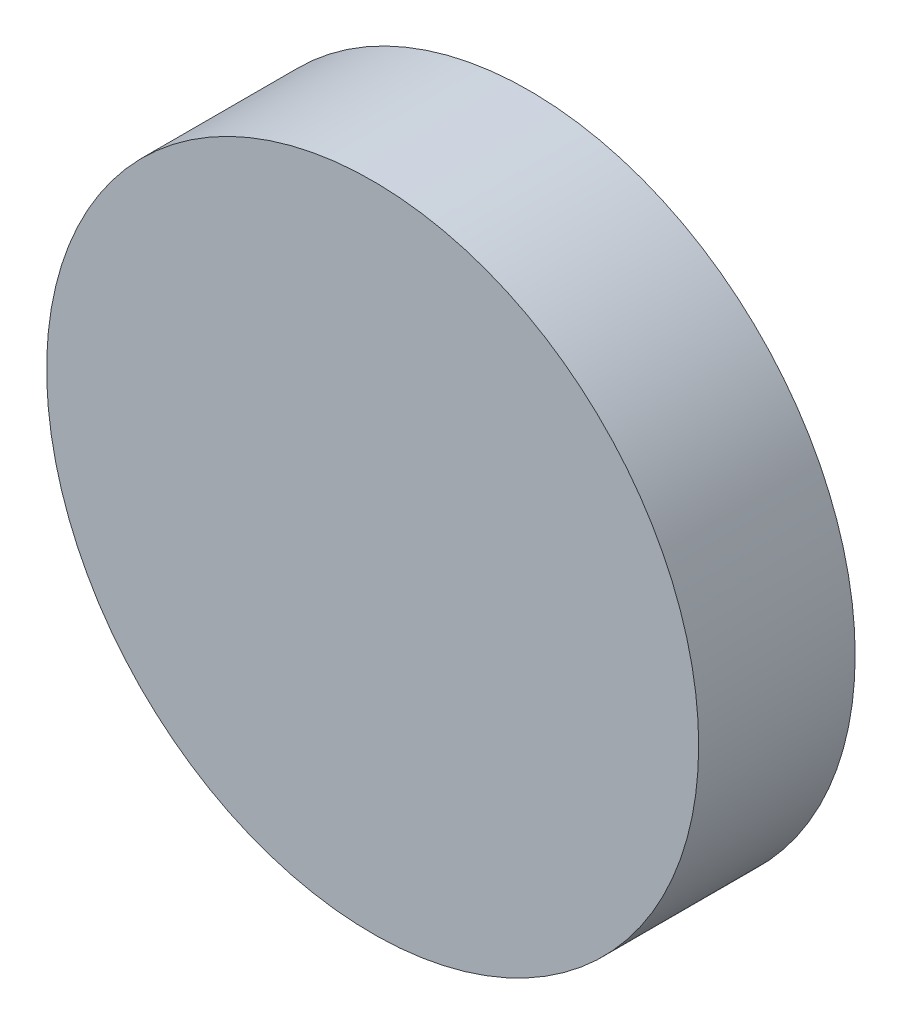
from build123d import *

# Parameters (mm, degrees)
SKETCH_1_R      = 6.25
EXTRUDE_1_DEPTH = 3


with BuildPart() as part:
    # 草图1 → 凸台-拉伸1 (new body)
    with BuildSketch(Plane.XY):
        Circle(SKETCH_1_R)
    extrude(amount=EXTRUDE_1_DEPTH)


solid = part.part
